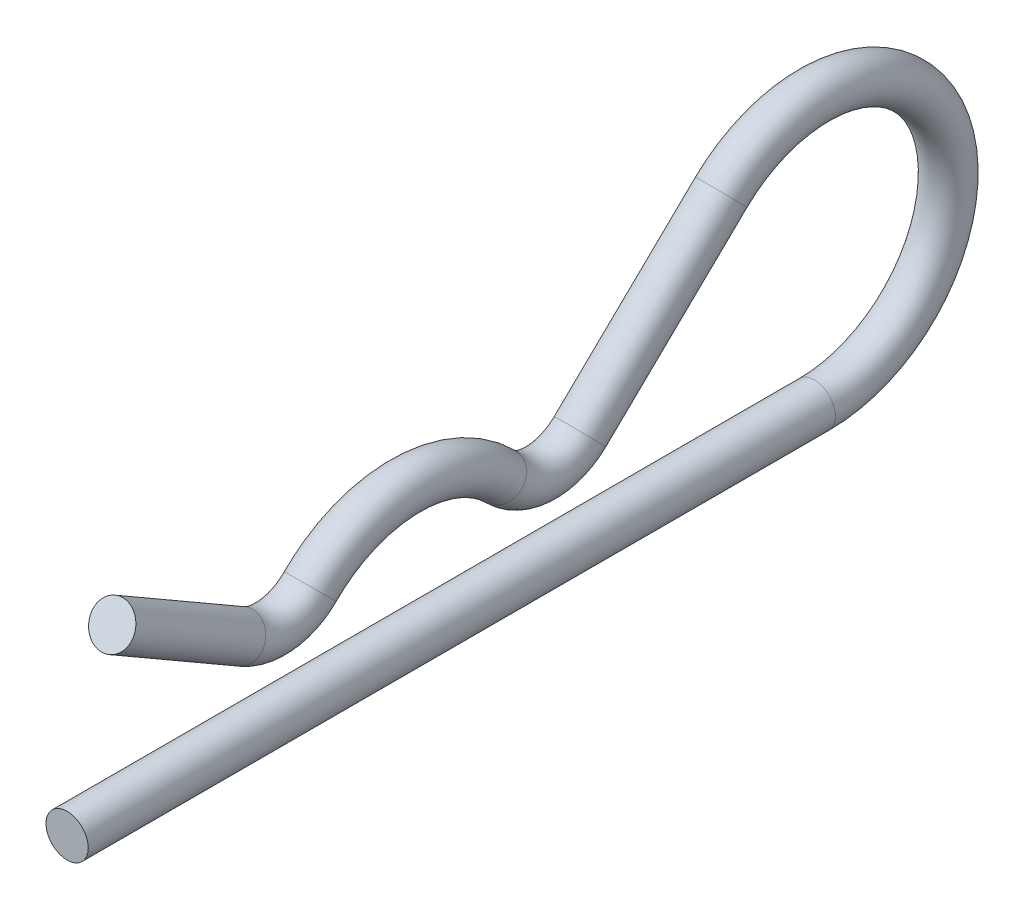
from build123d import *

# Parameters (mm, degrees)
SKETCH1_R = 0.5953125


with BuildPart() as part:
    # Sweep1: sweep along a path in Sketch2
    with BuildLine(Plane(origin=(0, 0, 0), x_dir=(0, 0, -1), z_dir=(1, 0, 0))) as sweep1_path:
        Line((0, 0), (21.034375, 0))
        ThreePointArc((21.034375, 0), (24.529244401, 5.184930545), (18.411830942, 6.479098023))
        Line((18.411830942, 6.479098023), (14.435920349, 2.629771227))
        ThreePointArc((14.435920349, 2.629771227), (13.315041787, 2.182899811), (12.203782747, 2.65318287))
        ThreePointArc((12.203782747, 2.65318287), (9.525, 3.7703125), (6.846217253, 2.65318287))
        ThreePointArc((6.846217253, 2.65318287), (5.929296784, 2.196895743), (4.924558728, 2.395497171))
        Line((4.924558728, 2.395497171), (1.27, 4.505457637))
    # Sketch1 → Sweep1 (sweep)
    with BuildSketch(Plane.XY):
        Circle(SKETCH1_R)
    sweep(path=sweep1_path.line)


solid = part.part
